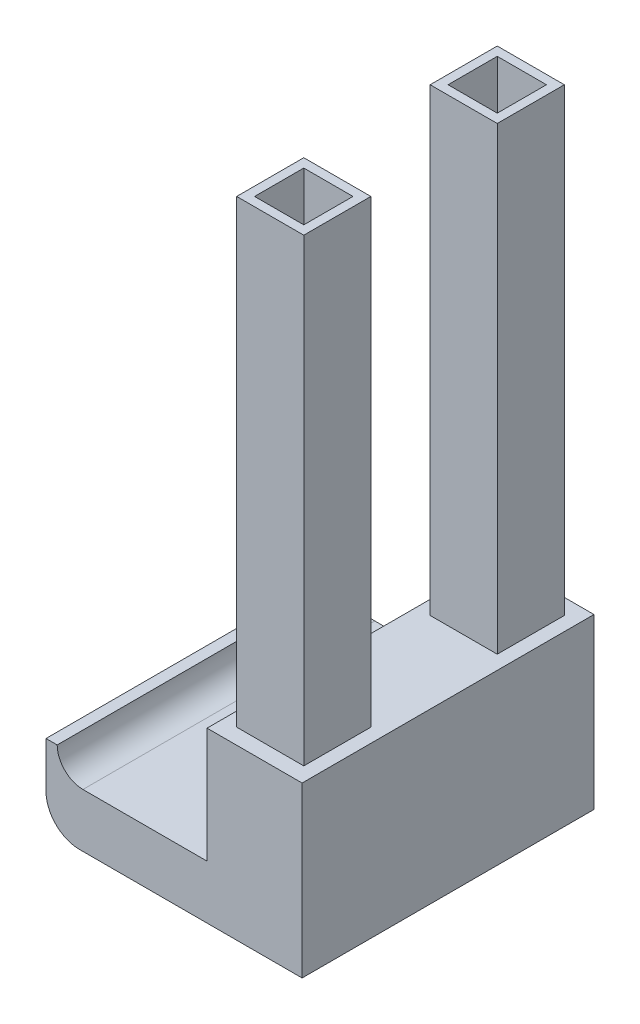
from build123d import *

# Parameters (mm, degrees)
BOSS_EXTRUDE1_DEPTH = 16.5735
SKETCH2_W           = 7.62
SKETCH2_H           = 7.62
SKETCH2_W_2         = 5.588
SKETCH2_H_2         = 5.588
BOSS_EXTRUDE2_DEPTH = 52.197


with BuildPart() as part:
    # Sketch1 → Boss-Extrude1 (new body, symmetric)
    with BuildSketch(Plane.XY):
        with BuildLine():
            Line((0, 0), (0, 19.177))
            Line((0, 19.177), (-10.795, 19.177))
            Line((-10.795, 19.177), (-10.795, 6.096))
            Line((-10.795, 6.096), (-24.892, 6.096))
            ThreePointArc((-24.892, 6.096), (-26.957458908, 6.951541092), (-27.813, 9.017))
            Line((-27.813, 9.017), (-29.083, 9.017))
            Line((-29.083, 9.017), (-29.083, 3.81))
            ThreePointArc((-29.083, 3.81), (-27.967076836, 1.115923164), (-25.273, 0))
            Line((-25.273, 0), (0, 0))
        make_face()
    extrude(amount=BOSS_EXTRUDE1_DEPTH, both=True)

    # Sketch2 → Boss-Extrude2 (add)
    with BuildSketch(Plane(origin=(0, 19.177, 0), x_dir=(1, 0, 0), z_dir=(0, 1, 0))):
        with Locations((-5.3975, 10.9855)):
            Rectangle(SKETCH2_W, SKETCH2_H)
        with Locations((-5.3975, 10.9855)):
            Rectangle(SKETCH2_W_2, SKETCH2_H_2, mode=Mode.SUBTRACT)
        with Locations((-5.3975, -10.9855)):
            Rectangle(SKETCH2_W, SKETCH2_H)
        with Locations((-5.3975, -10.9855)):
            Rectangle(SKETCH2_W_2, SKETCH2_H_2, mode=Mode.SUBTRACT)
    extrude(amount=BOSS_EXTRUDE2_DEPTH)


solid = part.part
